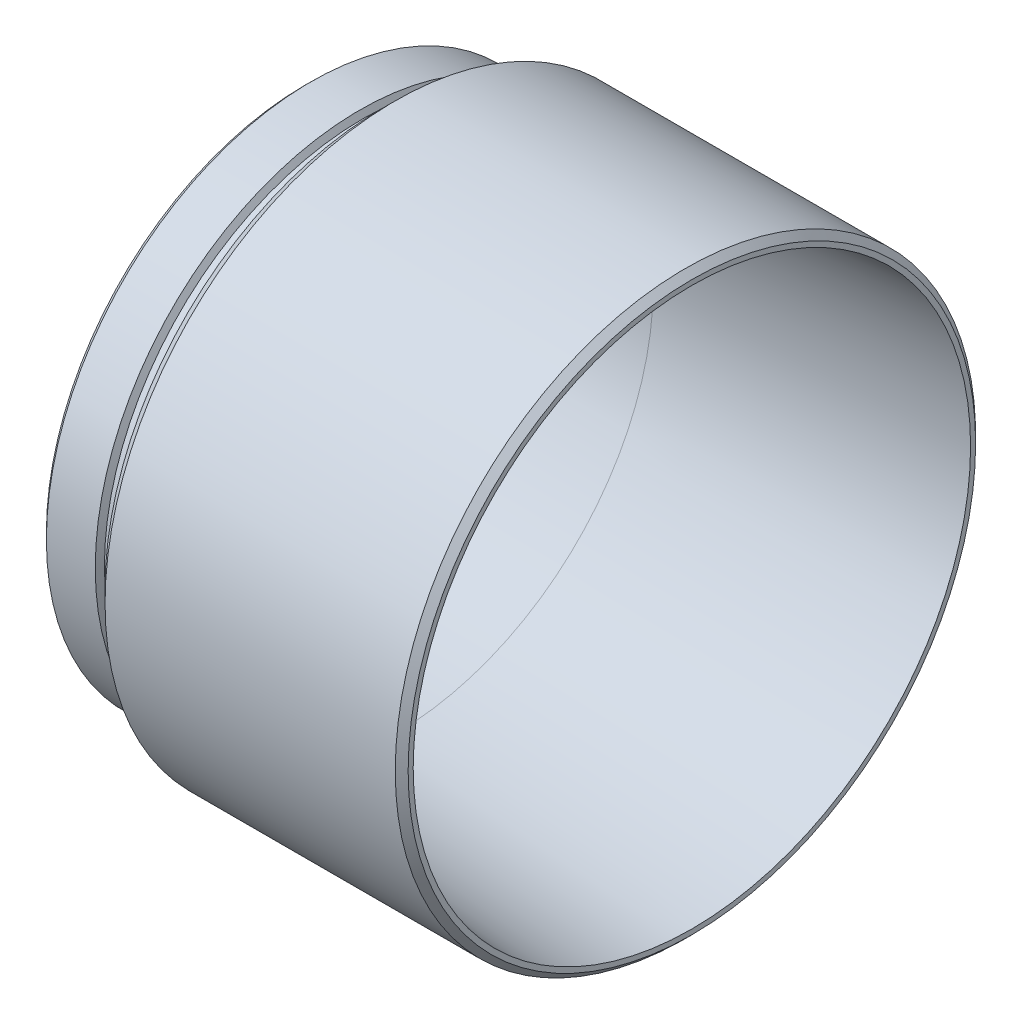
from build123d import *


with BuildPart() as part:
    # Esquisse1 → Révolution1 (revolve)
    with BuildSketch(Plane(origin=(0, 0, 0), x_dir=(1, 0, 0), z_dir=(0, 1, 0)), mode=Mode.PRIVATE) as r_volution1_sk:
        with BuildLine():
            Line((2, 40), (-12, 40))
            Line((-12, 40), (-12, 40.1))
            Line((-12, 40.1), (-11.1, 41))
            Line((-11.1, 41), (-3.519615242, 41))
            Line((-3.519615242, 41), (-3, 40.1))
            Line((-3, 40.1), (-0.5, 40.1))
            ThreePointArc((-0.5, 40.1), (-0.146446609, 40.246446609), (0, 40.6))
            Line((0, 40.6), (0, 43))
            Line((0, 43), (2, 45))
            Line((2, 45), (47, 45))
            Line((47, 45), (48, 44))
            Line((48, 44), (48, 43.216633349))
            Line((48, 43.216633349), (2, 40))
        make_face()
    revolve(r_volution1_sk.sketch.rotate(Axis((-32.094260439, 0, 0), (1, 0, 0)), 180), axis=Axis((-32.094260439, 0, 0), (1, 0, 0)))  # turned: the seam where the file's is


solid = part.part
